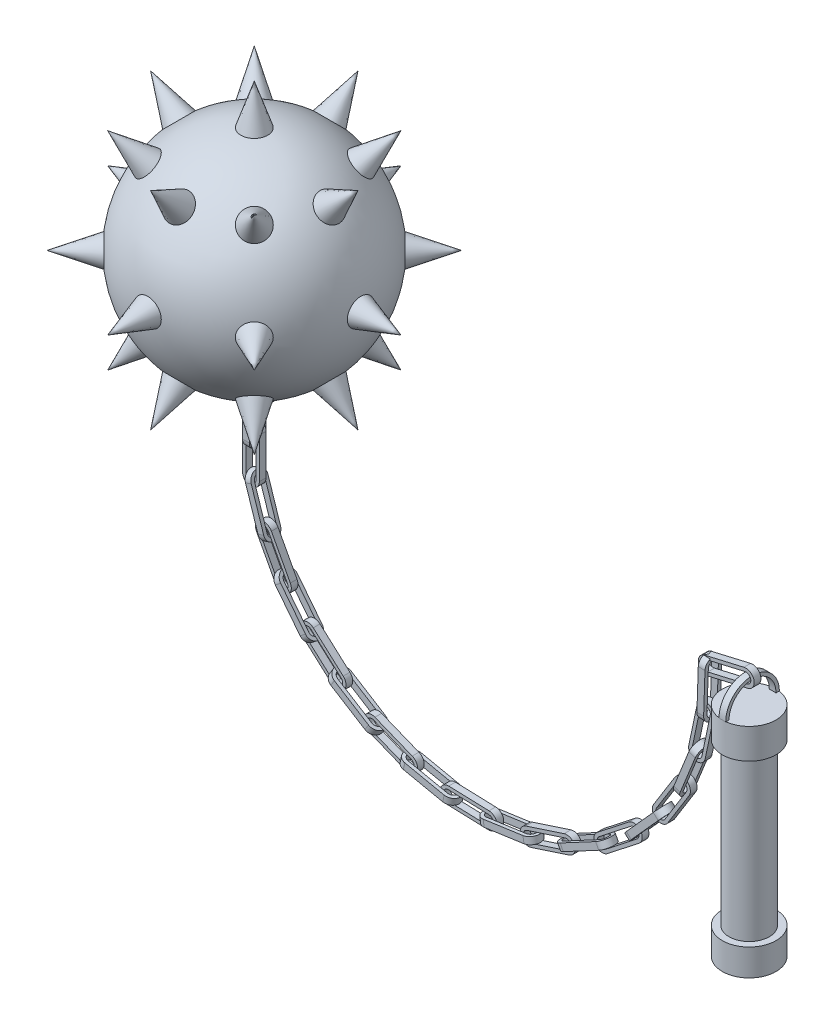
from build123d import *

# Parameters (mm, degrees)
SKETCH16_W                = 25.4
SKETCH16_H                = 3.226223006
BOSS_EXTRUDE1_DEPTH       = 3.175
BOSS_EXTRUDE1_DEPTH_BACK  = 3.175
BOSS_EXTRUDE2_DEPTH       = 3.175
BOSS_EXTRUDE2_DEPTH_BACK  = 3.175
BOSS_EXTRUDE3_DEPTH       = 3.175
BOSS_EXTRUDE3_DEPTH_BACK  = 3.175
BOSS_EXTRUDE4_DEPTH       = 3.175
BOSS_EXTRUDE4_DEPTH_BACK  = 2.54
BOSS_EXTRUDE5_DEPTH       = 3.175
BOSS_EXTRUDE5_DEPTH_BACK  = 3.175
BOSS_EXTRUDE6_DEPTH       = 3.175
BOSS_EXTRUDE6_DEPTH_BACK  = 3.175
BOSS_EXTRUDE7_DEPTH       = 3.175
BOSS_EXTRUDE7_DEPTH_BACK  = 3.175
BOSS_EXTRUDE8_DEPTH       = 3.175
BOSS_EXTRUDE8_DEPTH_BACK  = 3.175
BOSS_EXTRUDE9_DEPTH       = 3.175
BOSS_EXTRUDE9_DEPTH_BACK  = 3.175
BOSS_EXTRUDE10_DEPTH      = 3.175
BOSS_EXTRUDE10_DEPTH_BACK = 3.175
BOSS_EXTRUDE11_DEPTH      = 3.175
BOSS_EXTRUDE11_DEPTH_BACK = 3.175
BOSS_EXTRUDE12_DEPTH      = 3.175
BOSS_EXTRUDE12_DEPTH_BACK = 3.175
BOSS_EXTRUDE13_DEPTH      = 3.175
BOSS_EXTRUDE13_DEPTH_BACK = 3.175
BOSS_EXTRUDE14_DEPTH      = 3.175
BOSS_EXTRUDE14_DEPTH_BACK = 3.175
BOSS_EXTRUDE15_DEPTH      = 3.175
BOSS_EXTRUDE15_DEPTH_BACK = 3.175
BOSS_EXTRUDE16_DEPTH      = 3.175
BOSS_EXTRUDE16_DEPTH_BACK = 3.175
BOSS_EXTRUDE17_DEPTH      = 3.175
BOSS_EXTRUDE17_DEPTH_BACK = 3.175
BOSS_EXTRUDE18_DEPTH      = 3.175
BOSS_EXTRUDE18_DEPTH_BACK = 3.175
BOSS_EXTRUDE19_DEPTH      = 3.175
BOSS_EXTRUDE19_DEPTH_BACK = 3.175
BOSS_EXTRUDE20_DEPTH      = 3.175
BOSS_EXTRUDE20_DEPTH_BACK = 3.175
BOSS_EXTRUDE21_DEPTH      = 3.175
BOSS_EXTRUDE21_DEPTH_BACK = 3.175
SKETCH42_R                = 25.4
BOSS_EXTRUDE22_DEPTH      = 3.175
BOSS_EXTRUDE23_DEPTH      = 3.175
BOSS_EXTRUDE23_DEPTH_BACK = 3.175


with BuildPart() as part:
    # Sketch1 → Revolve1 (revolve)
    with BuildSketch(Plane.XY):
        with BuildLine():
            Line((0, 101.6), (0, -101.6))
            ThreePointArc((0, -101.6), (101.6, 0), (0, 101.6))
        make_face()
    revolve(axis=Axis((0, 101.6, 0), (0, -1, 0)))

    # Sketch6 → Revolve2 (revolve)
    with BuildSketch(Plane.XY, mode=Mode.PRIVATE) as revolve2_sk:
        Polygon((0, 100.803124952), (0, 138.903124952), (12.7, 100.803124952), align=None)
    revolve2 = revolve(revolve2_sk.sketch.rotate(Axis((0, 100.803124952, 0), (0, 1, 0)), 90), axis=Axis((0, 100.803124952, 0), (0, 1, 0)))

    # Mirror1: Revolve2 across plane
    add(revolve2.mirror(Plane(origin=(0, 0, 0), x_dir=(0, 0, 1), z_dir=(0.9238795325112864, -0.3826834323650908, 0))))

    # Mirror2: Revolve2 across plane
    add(revolve2.mirror(Plane(origin=(0, 0, 0), x_dir=(0, 0, 1), z_dir=(-0.3826834323650941, 0.9238795325112851, 0))))

    # Mirror2 copy 1 sketch → Mirror2 copy 1 (revolve)
    with BuildSketch(Plane(origin=(0, 0, 0), x_dir=(0, -1, 0), z_dir=(0, 0, 1))):
        Polygon((0, 100.803124952), (0, 138.903124952), (12.7, 100.803124952), align=None)
    revolve(axis=Axis((100.803124952, 0, 0), (1, 0, 0)))

    # CirPattern2 copy 1 sketch → CirPattern2 copy 1 (revolve)
    with BuildSketch(Plane(origin=(0, 0, 0), x_dir=(-0.49999999999999906, 0.7071067811865491, 0.49999999999999895), z_dir=(0.7071067811865475, 0, 0.7071067811865476))):
        Polygon((0, -100.803124952), (0, -138.903124952), (12.7, -100.803124952), align=None)
    revolve(axis=Axis((50.401562476, 71.278573218, -50.401562476), (-0.5000000000000012, -0.7071067811865459, 0.5000000000000011)))

    # CirPattern2 copy 2 sketch → CirPattern2 copy 2 (revolve)
    with BuildSketch(Plane(origin=(0, 0, 0), x_dir=(0, 0.7071067811865491, 0.7071067811865461), z_dir=(1, 0, 0))):
        Polygon((0, -100.803124952), (0, -138.903124952), (12.7, -100.803124952), align=None)
    revolve(axis=Axis((0, 71.278573218, -71.278573218), (0, -0.7071067811865459, 0.7071067811865491)))

    # CirPattern2 copy 3 sketch → CirPattern2 copy 3 (revolve)
    with BuildSketch(Plane(origin=(0, 0, 0), x_dir=(0.49999999999999895, 0.7071067811865491, 0.49999999999999906), z_dir=(0.7071067811865476, 0, -0.7071067811865475))):
        Polygon((0, -100.803124952), (0, -138.903124952), (12.7, -100.803124952), align=None)
    revolve(axis=Axis((-50.401562476, 71.278573218, -50.401562476), (0.5000000000000011, -0.7071067811865459, 0.5000000000000012)))

    # CirPattern2 copy 4 sketch → CirPattern2 copy 4 (revolve)
    with BuildSketch(Plane(origin=(0, 0, 0), x_dir=(0.7071067811865461, 0.7071067811865491, 0), z_dir=(0, 0, -1))):
        Polygon((0, -100.803124952), (0, -138.903124952), (12.7, -100.803124952), align=None)
    revolve(axis=Axis((-71.278573218, 71.278573218, 0), (0.7071067811865491, -0.7071067811865459, 0)))

    # CirPattern2 copy 5 sketch → CirPattern2 copy 5 (revolve)
    with BuildSketch(Plane(origin=(0, 0, 0), x_dir=(0.4999999999999991, 0.7071067811865491, -0.49999999999999895), z_dir=(-0.7071067811865475, 0, -0.7071067811865477))):
        Polygon((0, -100.803124952), (0, -138.903124952), (12.7, -100.803124952), align=None)
    revolve(axis=Axis((-50.401562476, 71.278573218, 50.401562476), (0.5000000000000012, -0.7071067811865459, -0.5000000000000011)))

    # CirPattern2 copy 6 sketch → CirPattern2 copy 6 (revolve)
    with BuildSketch(Plane(origin=(0, 0, 0), x_dir=(0, 0.7071067811865491, -0.7071067811865461), z_dir=(-1, 0, 0))):
        Polygon((0, -100.803124952), (0, -138.903124952), (12.7, -100.803124952), align=None)
    revolve(axis=Axis((0, 71.278573218, 71.278573218), (0, -0.7071067811865459, -0.7071067811865491)))

    # CirPattern2 copy 7 sketch → CirPattern2 copy 7 (revolve)
    with BuildSketch(Plane(origin=(0, 0, 0), x_dir=(-0.4999999999999989, 0.7071067811865491, -0.4999999999999991), z_dir=(-0.7071067811865477, 0, 0.7071067811865474))):
        Polygon((0, -100.803124952), (0, -138.903124952), (12.7, -100.803124952), align=None)
    revolve(axis=Axis((50.401562476, 71.278573218, 50.401562476), (-0.500000000000001, -0.7071067811865459, -0.5000000000000012)))

    # CirPattern2 copy 8 sketch → CirPattern2 copy 8 (revolve)
    with BuildSketch(Plane(origin=(0, 0, 0), x_dir=(0.7071067811865476, 0, -0.7071067811865475), z_dir=(0.7071067811865475, 0, 0.7071067811865476))):
        Polygon((0, 100.803124952), (0, 138.903124952), (12.7, 100.803124952), align=None)
    revolve(axis=Axis((0, 100.803124952, 0), (0, 1, 0)))

    # CirPattern2 copy 9 sketch → CirPattern2 copy 9 (revolve)
    with BuildSketch(Plane(origin=(0, 0, 0), x_dir=(0, 0, -1), z_dir=(1, 0, 0))):
        Polygon((0, 100.803124952), (0, 138.903124952), (12.7, 100.803124952), align=None)
    revolve(axis=Axis((0, 100.803124952, 0), (0, 1, 0)))

    # CirPattern2 copy 10 sketch → CirPattern2 copy 10 (revolve)
    with BuildSketch(Plane(origin=(0, 0, 0), x_dir=(-0.7071067811865475, 0, -0.7071067811865476), z_dir=(0.7071067811865476, 0, -0.7071067811865475))):
        Polygon((0, 100.803124952), (0, 138.903124952), (12.7, 100.803124952), align=None)
    revolve(axis=Axis((0, 100.803124952, 0), (0, 1, 0)))

    # CirPattern2 copy 11 sketch → CirPattern2 copy 11 (revolve)
    with BuildSketch(Plane(origin=(0, 0, 0), x_dir=(-1, 0, 0), z_dir=(0, 0, -1))):
        Polygon((0, 100.803124952), (0, 138.903124952), (12.7, 100.803124952), align=None)
    revolve(axis=Axis((0, 100.803124952, 0), (0, 1, 0)))

    # CirPattern2 copy 12 sketch → CirPattern2 copy 12 (revolve)
    with BuildSketch(Plane(origin=(0, 0, 0), x_dir=(-0.7071067811865477, 0, 0.7071067811865475), z_dir=(-0.7071067811865475, 0, -0.7071067811865477))):
        Polygon((0, 100.803124952), (0, 138.903124952), (12.7, 100.803124952), align=None)
    revolve(axis=Axis((0, 100.803124952, 0), (0, 1, 0)))

    # CirPattern2 copy 13 sketch → CirPattern2 copy 13 (revolve)
    with BuildSketch(Plane.ZY):
        Polygon((0, 100.803124952), (0, 138.903124952), (12.7, 100.803124952), align=None)
    revolve(axis=Axis((0, 100.803124952, 0), (0, 1, 0)))

    # CirPattern2 copy 14 sketch → CirPattern2 copy 14 (revolve)
    with BuildSketch(Plane(origin=(0, 0, 0), x_dir=(0.7071067811865474, 0, 0.7071067811865477), z_dir=(-0.7071067811865477, 0, 0.7071067811865474))):
        Polygon((0, 100.803124952), (0, 138.903124952), (12.7, 100.803124952), align=None)
    revolve(axis=Axis((0, 100.803124952, 0), (0, 1, 0)))

    # CirPattern2 copy 15 sketch → CirPattern2 copy 15 (revolve)
    with BuildSketch(Plane(origin=(0, 0, 0), x_dir=(0.4999999999999953, 0.7071067811865542, -0.4999999999999952), z_dir=(0.7071067811865475, 0, 0.7071067811865476))):
        Polygon((0, -100.803124952), (0, -138.903124952), (12.7, -100.803124952), align=None)
    revolve(axis=Axis((50.401562476, -71.278573218, -50.401562476), (-0.5000000000000048, 0.7071067811865412, 0.5000000000000047)))

    # CirPattern2 copy 16 sketch → CirPattern2 copy 16 (revolve)
    with BuildSketch(Plane(origin=(0, 0, 0), x_dir=(0, 0.7071067811865542, -0.7071067811865408), z_dir=(1, 0, 0))):
        Polygon((0, -100.803124952), (0, -138.903124952), (12.7, -100.803124952), align=None)
    revolve(axis=Axis((0, -71.278573218, -71.278573218), (0, 0.7071067811865412, 0.7071067811865542)))

    # CirPattern2 copy 17 sketch → CirPattern2 copy 17 (revolve)
    with BuildSketch(Plane(origin=(0, 0, 0), x_dir=(-0.4999999999999952, 0.7071067811865542, -0.4999999999999953), z_dir=(0.7071067811865476, 0, -0.7071067811865475))):
        Polygon((0, -100.803124952), (0, -138.903124952), (12.7, -100.803124952), align=None)
    revolve(axis=Axis((-50.401562476, -71.278573218, -50.401562476), (0.5000000000000047, 0.7071067811865412, 0.5000000000000048)))

    # CirPattern2 copy 18 sketch → CirPattern2 copy 18 (revolve)
    with BuildSketch(Plane(origin=(0, 0, 0), x_dir=(-0.7071067811865408, 0.7071067811865542, 0), z_dir=(0, 0, -1))):
        Polygon((0, -100.803124952), (0, -138.903124952), (12.7, -100.803124952), align=None)
    revolve(axis=Axis((-71.278573218, -71.278573218, 0), (0.7071067811865542, 0.7071067811865412, 0)))

    # CirPattern2 copy 19 sketch → CirPattern2 copy 19 (revolve)
    with BuildSketch(Plane(origin=(0, 0, 0), x_dir=(-0.49999999999999534, 0.7071067811865542, 0.4999999999999952), z_dir=(-0.7071067811865475, 0, -0.7071067811865477))):
        Polygon((0, -100.803124952), (0, -138.903124952), (12.7, -100.803124952), align=None)
    revolve(axis=Axis((-50.401562476, -71.278573218, 50.401562476), (0.5000000000000049, 0.7071067811865412, -0.5000000000000047)))

    # CirPattern2 copy 20 sketch → CirPattern2 copy 20 (revolve)
    with BuildSketch(Plane(origin=(0, 0, 0), x_dir=(0, 0.7071067811865542, 0.7071067811865408), z_dir=(-1, 0, 0))):
        Polygon((0, -100.803124952), (0, -138.903124952), (12.7, -100.803124952), align=None)
    revolve(axis=Axis((0, -71.278573218, 71.278573218), (0, 0.7071067811865412, -0.7071067811865542)))

    # CirPattern2 copy 21 sketch → CirPattern2 copy 21 (revolve)
    with BuildSketch(Plane(origin=(0, 0, 0), x_dir=(0.4999999999999951, 0.7071067811865542, 0.49999999999999534), z_dir=(-0.7071067811865477, 0, 0.7071067811865474))):
        Polygon((0, -100.803124952), (0, -138.903124952), (12.7, -100.803124952), align=None)
    revolve(axis=Axis((50.401562476, -71.278573218, 50.401562476), (-0.5000000000000047, 0.7071067811865412, -0.5000000000000049)))

    # CirPattern2 copy 22 sketch → CirPattern2 copy 22 (revolve)
    with BuildSketch(Plane(origin=(0, 0, 0), x_dir=(0, -1, 0), z_dir=(0.7071067811865475, 0, 0.7071067811865476))):
        Polygon((0, 100.803124952), (0, 138.903124952), (12.7, 100.803124952), align=None)
    revolve(axis=Axis((71.278573218, 0, -71.278573218), (0.7071067811865476, 1.149080830487037e-14, -0.7071067811865475)))

    # CirPattern2 copy 23 sketch → CirPattern2 copy 23 (revolve)
    with BuildSketch(Plane(origin=(0, 0, 0), x_dir=(0, -1, 0), z_dir=(1, 0, 0))):
        Polygon((0, 100.803124952), (0, 138.903124952), (12.7, 100.803124952), align=None)
    revolve(axis=Axis((0, 0, -100.803124952), (0, 0, -1)))

    # CirPattern2 copy 24 sketch → CirPattern2 copy 24 (revolve)
    with BuildSketch(Plane(origin=(0, 0, 0), x_dir=(0, -1, 0), z_dir=(0.7071067811865476, 0, -0.7071067811865475))):
        Polygon((0, 100.803124952), (0, 138.903124952), (12.7, 100.803124952), align=None)
    revolve(axis=Axis((-71.278573218, 0, -71.278573218), (-0.7071067811865475, 1.149080830487037e-14, -0.7071067811865476)))

    # CirPattern2 copy 25 sketch → CirPattern2 copy 25 (revolve)
    with BuildSketch(Plane(origin=(0, 0, 0), x_dir=(0, -1, 0), z_dir=(0, 0, -1))):
        Polygon((0, 100.803124952), (0, 138.903124952), (12.7, 100.803124952), align=None)
    revolve(axis=Axis((-100.803124952, 0, 0), (-1, 0, 0)))

    # CirPattern2 copy 26 sketch → CirPattern2 copy 26 (revolve)
    with BuildSketch(Plane(origin=(0, 0, 0), x_dir=(0, -1, 0), z_dir=(-0.7071067811865475, 0, -0.7071067811865477))):
        Polygon((0, 100.803124952), (0, 138.903124952), (12.7, 100.803124952), align=None)
    revolve(axis=Axis((-71.278573218, 0, 71.278573218), (-0.7071067811865477, 1.149080830487037e-14, 0.7071067811865475)))

    # CirPattern2 copy 27 sketch → CirPattern2 copy 27 (revolve)
    with BuildSketch(Plane(origin=(0, 0, 0), x_dir=(0, -1, 0), z_dir=(-1, 0, 0))):
        Polygon((0, 100.803124952), (0, 138.903124952), (12.7, 100.803124952), align=None)
    revolve(axis=Axis((0, 0, 100.803124952), (0, 0, 1)))

    # CirPattern2 copy 28 sketch → CirPattern2 copy 28 (revolve)
    with BuildSketch(Plane(origin=(0, 0, 0), x_dir=(0, -1, 0), z_dir=(-0.7071067811865477, 0, 0.7071067811865474))):
        Polygon((0, 100.803124952), (0, 138.903124952), (12.7, 100.803124952), align=None)
    revolve(axis=Axis((71.278573218, 0, 71.278573218), (0.7071067811865474, 1.149080830487037e-14, 0.7071067811865477)))

    # CirPattern2 copy 29 sketch → CirPattern2 copy 29 (revolve)
    with BuildSketch(Plane(origin=(0, 0, 0), x_dir=(0.7071067811865476, 0, -0.7071067811865475), z_dir=(0.7071067811865475, 0, 0.7071067811865476))):
        Polygon((0, 100.803124952), (0, 138.903124952), (12.7, 100.803124952), align=None)
    revolve(axis=Axis((0, 100.803124952, 0), (0, 1, 0)))

    # CirPattern2 copy 30 sketch → CirPattern2 copy 30 (revolve)
    with BuildSketch(Plane(origin=(0, 0, 0), x_dir=(0, 0, -1), z_dir=(1, 0, 0))):
        Polygon((0, 100.803124952), (0, 138.903124952), (12.7, 100.803124952), align=None)
    revolve(axis=Axis((0, 100.803124952, 0), (0, 1, 0)))

    # CirPattern2 copy 31 sketch → CirPattern2 copy 31 (revolve)
    with BuildSketch(Plane(origin=(0, 0, 0), x_dir=(-0.7071067811865475, 0, -0.7071067811865476), z_dir=(0.7071067811865476, 0, -0.7071067811865475))):
        Polygon((0, 100.803124952), (0, 138.903124952), (12.7, 100.803124952), align=None)
    revolve(axis=Axis((0, 100.803124952, 0), (0, 1, 0)))

    # CirPattern2 copy 32 sketch → CirPattern2 copy 32 (revolve)
    with BuildSketch(Plane(origin=(0, 0, 0), x_dir=(-1, 0, 0), z_dir=(0, 0, -1))):
        Polygon((0, 100.803124952), (0, 138.903124952), (12.7, 100.803124952), align=None)
    revolve(axis=Axis((0, 100.803124952, 0), (0, 1, 0)))

    # CirPattern2 copy 33 sketch → CirPattern2 copy 33 (revolve)
    with BuildSketch(Plane(origin=(0, 0, 0), x_dir=(-0.7071067811865477, 0, 0.7071067811865475), z_dir=(-0.7071067811865475, 0, -0.7071067811865477))):
        Polygon((0, 100.803124952), (0, 138.903124952), (12.7, 100.803124952), align=None)
    revolve(axis=Axis((0, 100.803124952, 0), (0, 1, 0)))

    # CirPattern2 copy 34 sketch → CirPattern2 copy 34 (revolve)
    with BuildSketch(Plane.ZY):
        Polygon((0, 100.803124952), (0, 138.903124952), (12.7, 100.803124952), align=None)
    revolve(axis=Axis((0, 100.803124952, 0), (0, 1, 0)))

    # CirPattern2 copy 35 sketch → CirPattern2 copy 35 (revolve)
    with BuildSketch(Plane(origin=(0, 0, 0), x_dir=(0.7071067811865474, 0, 0.7071067811865477), z_dir=(-0.7071067811865477, 0, 0.7071067811865474))):
        Polygon((0, 100.803124952), (0, 138.903124952), (12.7, 100.803124952), align=None)
    revolve(axis=Axis((0, 100.803124952, 0), (0, 1, 0)))

    # Sketch16 → Revolve3 (revolve)
    with BuildSketch(Plane.XY):
        with Locations((12.7, -99.986888497)):
            Rectangle(SKETCH16_W, SKETCH16_H)
    revolve(axis=Axis((0, -98.373776994, 0), (0, -1, 0)))

    # Sketch17 → Boss-Extrude1 (add, two sides)
    with BuildSketch(Plane.XY) as boss_extrude1_sk:
        with BuildLine():
            Line((-22.225, -101.6), (-19.05, -101.6))
            ThreePointArc((-19.05, -101.6), (0, -120.65), (19.05, -101.6))
            Line((19.05, -101.6), (22.225, -101.6))
            ThreePointArc((22.225, -101.6), (0, -123.825), (-22.225, -101.6))
        make_face()
    extrude(amount=BOSS_EXTRUDE1_DEPTH)
    extrude(boss_extrude1_sk.sketch, amount=-BOSS_EXTRUDE1_DEPTH_BACK)


with BuildPart() as body_2:
    # Sketch18 → Boss-Extrude2 (new, two sides)
    with BuildSketch(Plane(origin=(0, 0, 0), x_dir=(0, 0, -1), z_dir=(1, 0, 0))) as boss_extrude2_sk:
        with BuildLine():
            Line((7.9375, -114.3), (7.9375, -152.4))
            ThreePointArc((7.9375, -152.4), (0, -160.3375), (-7.9375, -152.4))
            Line((-7.9375, -152.4), (-7.9375, -114.3))
            ThreePointArc((-7.9375, -114.3), (0, -106.3625), (7.9375, -114.3))
        make_face()
        with BuildLine():
            Line((4.7625, -114.3), (4.7625, -152.4))
            ThreePointArc((4.7625, -152.4), (0, -157.1625), (-4.7625, -152.4))
            Line((-4.7625, -152.4), (-4.7625, -114.3))
            ThreePointArc((-4.7625, -114.3), (0, -109.5375), (4.7625, -114.3))
        make_face(mode=Mode.SUBTRACT)
    extrude(amount=BOSS_EXTRUDE2_DEPTH)
    extrude(boss_extrude2_sk.sketch, amount=-BOSS_EXTRUDE2_DEPTH_BACK)


with BuildPart() as body_3:
    # Sketch19 → Boss-Extrude3 (new, two sides)
    with BuildSketch(Plane.XY) as boss_extrude3_sk:
        with BuildLine():
            Line((7.9375, -146.05), (7.9375, -184.15))
            ThreePointArc((7.9375, -184.15), (0, -192.0875), (-7.9375, -184.15))
            Line((-7.9375, -184.15), (-7.9375, -146.05))
            ThreePointArc((-7.9375, -146.05), (0, -138.1125), (7.9375, -146.05))
        make_face()
        with BuildLine():
            Line((4.7625, -146.05), (4.7625, -184.15))
            ThreePointArc((4.7625, -184.15), (0, -188.9125), (-4.7625, -184.15))
            Line((-4.7625, -184.15), (-4.7625, -146.05))
            ThreePointArc((-4.7625, -146.05), (0, -141.2875), (4.7625, -146.05))
        make_face(mode=Mode.SUBTRACT)
    extrude(amount=BOSS_EXTRUDE3_DEPTH)
    extrude(boss_extrude3_sk.sketch, amount=-BOSS_EXTRUDE3_DEPTH_BACK)


with BuildPart() as body_4:
    # Sketch23 → Boss-Extrude4 (new, two sides)
    with BuildSketch(Plane(origin=(-52.514645137, -17.161121629, 0), x_dir=(0, 0, 1), z_dir=(-0.950533423254603, -0.31062229681058945, 0))) as boss_extrude4_sk:
        with BuildLine():
            Line((7.9375, -177.506294373), (7.9375, -215.606294373))
            ThreePointArc((7.9375, -215.606294373), (0, -223.543794373), (-7.9375, -215.606294373))
            Line((-7.9375, -215.606294373), (-7.9375, -177.506294373))
            ThreePointArc((-7.9375, -177.506294373), (0, -169.568794373), (7.9375, -177.506294373))
        make_face()
        with BuildLine():
            Line((4.7625, -177.506294373), (4.7625, -215.606294373))
            ThreePointArc((4.7625, -215.606294373), (0, -220.368794373), (-4.7625, -215.606294373))
            Line((-4.7625, -215.606294373), (-4.7625, -177.506294373))
            ThreePointArc((-4.7625, -177.506294373), (0, -172.743794373), (4.7625, -177.506294373))
        make_face(mode=Mode.SUBTRACT)
    extrude(amount=BOSS_EXTRUDE4_DEPTH)
    extrude(boss_extrude4_sk.sketch, amount=-BOSS_EXTRUDE4_DEPTH_BACK)


with BuildPart() as body_5:
    # Sketch24 → Boss-Extrude5 (new, two sides)
    with BuildSketch(Plane.XY) as boss_extrude5_sk:
        with BuildLine():
            Line((19.347011601, -219.054210709), (37.290650196, -252.664266257))
            ThreePointArc((37.290650196, -252.664266257), (34.026813331, -263.404619204), (23.286460384, -260.140782338))
            Line((23.286460384, -260.140782338), (5.342821789, -226.53072679))
            ThreePointArc((5.342821789, -226.53072679), (8.606658654, -215.790373843), (19.347011601, -219.054210709))
        make_face()
        with BuildLine():
            Line((16.546173638, -220.549513925), (34.489812234, -254.159569473))
            ThreePointArc((34.489812234, -254.159569473), (32.531510114, -260.603781241), (26.087298347, -258.645479122))
            Line((26.087298347, -258.645479122), (8.143659751, -225.035423574))
            ThreePointArc((8.143659751, -225.035423574), (10.101961871, -218.591211806), (16.546173638, -220.549513925))
        make_face(mode=Mode.SUBTRACT)
    extrude(amount=BOSS_EXTRUDE5_DEPTH)
    extrude(boss_extrude5_sk.sketch, amount=-BOSS_EXTRUDE5_DEPTH_BACK)


with BuildPart() as body_6:
    # Sketch25 → Boss-Extrude6 (new, two sides)
    with BuildSketch(Plane(origin=(-104.793813262, -82.159208682, 0), x_dir=(0, 0, 1), z_dir=(-0.7869701611674117, -0.6169910578218603, 0))) as boss_extrude6_sk:
        with BuildLine():
            Line((7.9375, -219.090571228), (7.9375, -257.190571228))
            ThreePointArc((7.9375, -257.190571228), (0, -265.128071228), (-7.9375, -257.190571228))
            Line((-7.9375, -257.190571228), (-7.9375, -219.090571228))
            ThreePointArc((-7.9375, -219.090571228), (0, -211.153071228), (7.9375, -219.090571228))
        make_face()
        with BuildLine():
            Line((4.7625, -219.090571228), (4.7625, -257.190571228))
            ThreePointArc((4.7625, -257.190571228), (0, -261.953071228), (-4.7625, -257.190571228))
            Line((-4.7625, -257.190571228), (-4.7625, -219.090571228))
            ThreePointArc((-4.7625, -219.090571228), (0, -214.328071228), (4.7625, -219.090571228))
        make_face(mode=Mode.SUBTRACT)
    extrude(amount=BOSS_EXTRUDE6_DEPTH)
    extrude(boss_extrude6_sk.sketch, amount=-BOSS_EXTRUDE6_DEPTH_BACK)


with BuildPart() as body_7:
    # Sketch26 → Boss-Extrude7 (new, two sides)
    with BuildSketch(Plane.XY) as boss_extrude7_sk:
        with BuildLine():
            Line((59.032184082, -278.449346859), (87.389004876, -303.895382198))
            ThreePointArc((87.389004876, -303.895382198), (87.995418512, -315.104310559), (76.786490151, -315.710724195))
            Line((76.786490151, -315.710724195), (48.429669357, -290.264688856))
            ThreePointArc((48.429669357, -290.264688856), (47.823255721, -279.055760495), (59.032184082, -278.449346859))
        make_face()
        with BuildLine():
            Line((56.911681137, -280.812415259), (85.268501931, -306.258450597))
            ThreePointArc((85.268501931, -306.258450597), (85.632350113, -312.983807614), (78.906993096, -313.347655796))
            Line((78.906993096, -313.347655796), (50.550172302, -287.901620457))
            ThreePointArc((50.550172302, -287.901620457), (50.186324121, -281.17626344), (56.911681137, -280.812415259))
        make_face(mode=Mode.SUBTRACT)
    extrude(amount=BOSS_EXTRUDE7_DEPTH)
    extrude(boss_extrude7_sk.sketch, amount=-BOSS_EXTRUDE7_DEPTH_BACK)


with BuildPart() as body_8:
    # Sketch27 → Boss-Extrude8 (new, two sides)
    with BuildSketch(Plane(origin=(-116.067521977, -186.446603015, 0), x_dir=(-0.8489415914415972, 0.528486683200824, 0), z_dir=(-0.528486683200824, -0.8489415914415972, 0))) as boss_extrude8_sk:
        with BuildLine():
            Line((-271.514491041, 7.9375), (-233.414491041, 7.9375))
            ThreePointArc((-233.414491041, 7.9375), (-225.476991041, 0), (-233.414491041, -7.9375))
            Line((-233.414491041, -7.9375), (-271.514491041, -7.9375))
            ThreePointArc((-271.514491041, -7.9375), (-279.451991041, 0), (-271.514491041, 7.9375))
        make_face()
        with BuildLine():
            Line((-271.514491041, 4.7625), (-233.414491041, 4.7625))
            ThreePointArc((-233.414491041, 4.7625), (-228.651991041, 0), (-233.414491041, -4.7625))
            Line((-233.414491041, -4.7625), (-271.514491041, -4.7625))
            ThreePointArc((-271.514491041, -4.7625), (-276.276991041, 0), (-271.514491041, 4.7625))
        make_face(mode=Mode.SUBTRACT)
    extrude(amount=BOSS_EXTRUDE8_DEPTH)
    extrude(boss_extrude8_sk.sketch, amount=-BOSS_EXTRUDE8_DEPTH_BACK)


with BuildPart() as body_9:
    # Sketch28 → Boss-Extrude9 (new, two sides)
    with BuildSketch(Plane.XY) as boss_extrude9_sk:
        with BuildLine():
            Line((117.39343209, -322.57386418), (152.743183992, -336.786711904))
            ThreePointArc((152.743183992, -336.786711904), (157.146705696, -347.112253493), (146.821164107, -351.515775197))
            Line((146.821164107, -351.515775197), (111.471412205, -337.302927473))
            ThreePointArc((111.471412205, -337.302927473), (107.067890501, -326.977385884), (117.39343209, -322.57386418))
        make_face()
        with BuildLine():
            Line((116.209028113, -325.519676839), (151.558780015, -339.732524563))
            ThreePointArc((151.558780015, -339.732524563), (154.200893038, -345.927849516), (148.005568084, -348.569962539))
            Line((148.005568084, -348.569962539), (112.655816182, -334.357114814))
            ThreePointArc((112.655816182, -334.357114814), (110.01370316, -328.161789861), (116.209028113, -325.519676839))
        make_face(mode=Mode.SUBTRACT)
    extrude(amount=BOSS_EXTRUDE9_DEPTH)
    extrude(boss_extrude9_sk.sketch, amount=-BOSS_EXTRUDE9_DEPTH_BACK)


with BuildPart() as body_10:
    # Sketch29 → Boss-Extrude10 (new, two sides)
    with BuildSketch(Plane(origin=(-63.086034486, -299.280214714, 0), x_dir=(-0.978497240089968, 0.2062599116074561, 0), z_dir=(-0.20625991160745613, -0.9784972400899681, 0))) as boss_extrude10_sk:
        with BuildLine():
            Line((-255.646048997, 7.9375), (-217.546048997, 7.9375))
            ThreePointArc((-217.546048997, 7.9375), (-209.608548997, 0), (-217.546048997, -7.9375))
            Line((-217.546048997, -7.9375), (-255.646048997, -7.9375))
            ThreePointArc((-255.646048997, -7.9375), (-263.583548997, 0), (-255.646048997, 7.9375))
        make_face()
        with BuildLine():
            Line((-255.646048997, 4.7625), (-217.546048997, 4.7625))
            ThreePointArc((-217.546048997, 4.7625), (-212.783548997, 0), (-217.546048997, -4.7625))
            Line((-217.546048997, -4.7625), (-255.646048997, -4.7625))
            ThreePointArc((-255.646048997, -4.7625), (-260.408548997, 0), (-255.646048997, 4.7625))
        make_face(mode=Mode.SUBTRACT)
    extrude(amount=BOSS_EXTRUDE10_DEPTH)
    extrude(boss_extrude10_sk.sketch, amount=-BOSS_EXTRUDE10_DEPTH_BACK)


with BuildPart() as body_11:
    # Sketch30 → Boss-Extrude11 (new, two sides)
    with BuildSketch(Plane.XY) as boss_extrude11_sk:
        with BuildLine():
            Line((187.326539921, -344.076625094), (225.405521146, -345.342006009))
            ThreePointArc((225.405521146, -345.342006009), (233.075021211, -353.538748121), (224.878279099, -361.208248186))
            Line((224.878279099, -361.208248186), (186.799297874, -359.942867272))
            ThreePointArc((186.799297874, -359.942867272), (179.129797809, -351.746125159), (187.326539921, -344.076625094))
        make_face()
        with BuildLine():
            Line((187.221091512, -347.24987353), (225.300072737, -348.515254444))
            ThreePointArc((225.300072737, -348.515254444), (229.901772776, -353.433299712), (224.983727508, -358.034999751))
            Line((224.983727508, -358.034999751), (186.904746283, -356.769618836))
            ThreePointArc((186.904746283, -356.769618836), (182.303046244, -351.851573569), (187.221091512, -347.24987353))
        make_face(mode=Mode.SUBTRACT)
    extrude(amount=BOSS_EXTRUDE11_DEPTH)
    extrude(boss_extrude11_sk.sketch, amount=-BOSS_EXTRUDE11_DEPTH_BACK)


with BuildPart() as body_12:
    # Sketch31 → Boss-Extrude12 (new, two sides)
    with BuildSketch(Plane(origin=(53.727189599, -377.661093288, 0), x_dir=(-0.9900316805022418, -0.1408448493978644, 0), z_dir=(0.1408448493978644, -0.9900316805022418, 0))) as boss_extrude12_sk:
        with BuildLine():
            Line((-211.240631658, 7.9375), (-173.140631658, 7.9375))
            ThreePointArc((-173.140631658, 7.9375), (-165.203131658, 0), (-173.140631658, -7.9375))
            Line((-173.140631658, -7.9375), (-211.240631658, -7.9375))
            ThreePointArc((-211.240631658, -7.9375), (-219.178131658, 0), (-211.240631658, 7.9375))
        make_face()
        with BuildLine():
            Line((-211.240631658, 4.7625), (-173.140631658, 4.7625))
            ThreePointArc((-173.140631658, 4.7625), (-168.378131658, 0), (-173.140631658, -4.7625))
            Line((-173.140631658, -4.7625), (-211.240631658, -4.7625))
            ThreePointArc((-211.240631658, -4.7625), (-216.003131658, 0), (-211.240631658, 4.7625))
        make_face(mode=Mode.SUBTRACT)
    extrude(amount=BOSS_EXTRUDE12_DEPTH)
    extrude(boss_extrude12_sk.sketch, amount=-BOSS_EXTRUDE12_DEPTH_BACK)


with BuildPart() as body_13:
    # Sketch33 → Boss-Extrude13 (new, two sides)
    with BuildSketch(Plane.XY) as boss_extrude13_sk:
        with BuildLine():
            Line((260.396542669, -340.364079288), (296.611866095, -328.52936978))
            ThreePointArc((296.611866095, -328.52936978), (306.622289623, -333.608664346), (301.542995057, -343.619087874))
            Line((301.542995057, -343.619087874), (265.327671631, -355.453797382))
            ThreePointArc((265.327671631, -355.453797382), (255.317248103, -350.374502816), (260.396542669, -340.364079288))
        make_face()
        with BuildLine():
            Line((261.382768461, -343.382022907), (297.598091887, -331.547313399))
            ThreePointArc((297.598091887, -331.547313399), (303.604346004, -334.594890138), (300.556769264, -340.601144255))
            Line((300.556769264, -340.601144255), (264.341445838, -352.435853764))
            ThreePointArc((264.341445838, -352.435853764), (258.335191721, -349.388277024), (261.382768461, -343.382022907))
        make_face(mode=Mode.SUBTRACT)
    extrude(amount=BOSS_EXTRUDE13_DEPTH)
    extrude(boss_extrude13_sk.sketch, amount=-BOSS_EXTRUDE13_DEPTH_BACK)


with BuildPart() as body_14:
    # Sketch34 → Boss-Extrude14 (new, two sides)
    with BuildSketch(Plane(origin=(205.962414506, -385.786202487, 0), x_dir=(-0.8821536889344881, -0.4709616429172066, 0), z_dir=(0.4709616429172066, -0.8821536889344881, 0))) as boss_extrude14_sk:
        with BuildLine():
            Line((-105.554187709, -7.9375), (-143.654187709, -7.9375))
            ThreePointArc((-143.654187709, -7.9375), (-151.591687709, 0), (-143.654187709, 7.9375))
            Line((-143.654187709, 7.9375), (-105.554187709, 7.9375))
            ThreePointArc((-105.554187709, 7.9375), (-97.616687709, 0), (-105.554187709, -7.9375))
        make_face()
        with BuildLine():
            Line((-105.554187709, -4.7625), (-143.654187709, -4.7625))
            ThreePointArc((-143.654187709, -4.7625), (-148.416687709, 0), (-143.654187709, 4.7625))
            Line((-143.654187709, 4.7625), (-105.554187709, 4.7625))
            ThreePointArc((-105.554187709, 4.7625), (-100.791687709, 0), (-105.554187709, -4.7625))
        make_face(mode=Mode.SUBTRACT)
    extrude(amount=BOSS_EXTRUDE14_DEPTH)
    extrude(boss_extrude14_sk.sketch, amount=-BOSS_EXTRUDE14_DEPTH_BACK)


with BuildPart() as body_15:
    # Sketch35 → Boss-Extrude15 (new, two sides)
    with BuildSketch(Plane.XY) as boss_extrude15_sk:
        with BuildLine():
            Line((327.790119603, -311.884014578), (357.773682743, -288.376655275))
            ThreePointArc((357.773682743, -288.376655275), (368.917624919, -289.725864407), (367.568415786, -300.869806583))
            Line((367.568415786, -300.869806583), (337.584852645, -324.377165886))
            ThreePointArc((337.584852645, -324.377165886), (326.44091047, -323.027956753), (327.790119603, -311.884014578))
        make_face()
        with BuildLine():
            Line((329.749066211, -314.382644839), (359.732629352, -290.875285536))
            ThreePointArc((359.732629352, -290.875285536), (366.418994657, -291.684811016), (365.609469177, -298.371176321))
            Line((365.609469177, -298.371176321), (335.625906037, -321.878535624))
            ThreePointArc((335.625906037, -321.878535624), (328.939540731, -321.069010145), (329.749066211, -314.382644839))
        make_face(mode=Mode.SUBTRACT)
    extrude(amount=BOSS_EXTRUDE15_DEPTH)
    extrude(boss_extrude15_sk.sketch, amount=-BOSS_EXTRUDE15_DEPTH_BACK)


with BuildPart() as body_16:
    # Sketch36 → Boss-Extrude16 (new, two sides)
    with BuildSketch(Plane(origin=(347.350906536, -311.695852896, 0), x_dir=(0, 0, -1), z_dir=(0.7442735116471302, -0.6678749432793906, 0))) as boss_extrude16_sk:
        with BuildLine():
            Line((-7.9375, 22.93863976), (-7.9375, 61.03863976))
            ThreePointArc((-7.9375, 61.03863976), (0, 68.97613976), (7.9375, 61.03863976))
            Line((7.9375, 61.03863976), (7.9375, 22.93863976))
            ThreePointArc((7.9375, 22.93863976), (0, 15.00113976), (-7.9375, 22.93863976))
        make_face()
        with BuildLine():
            Line((-4.7625, 22.93863976), (-4.7625, 61.03863976))
            ThreePointArc((-4.7625, 61.03863976), (0, 65.80113976), (4.7625, 61.03863976))
            Line((4.7625, 61.03863976), (4.7625, 22.93863976))
            ThreePointArc((4.7625, 22.93863976), (0, 18.17613976), (-4.7625, 22.93863976))
        make_face(mode=Mode.SUBTRACT)
    extrude(amount=BOSS_EXTRUDE16_DEPTH)
    extrude(boss_extrude16_sk.sketch, amount=-BOSS_EXTRUDE16_DEPTH_BACK)


with BuildPart() as body_17:
    # Sketch37 → Boss-Extrude17 (new, two sides)
    with BuildSketch(Plane.XY) as boss_extrude17_sk:
        with BuildLine():
            Line((381.378610721, -262.071547087), (401.513953351, -229.726872453))
            ThreePointArc((401.513953351, -229.726872453), (412.447290281, -227.183261619), (414.990901115, -238.116598549))
            Line((414.990901115, -238.116598549), (394.855558485, -270.461273183))
            ThreePointArc((394.855558485, -270.461273183), (383.922221556, -273.004884017), (381.378610721, -262.071547087))
        make_face()
        with BuildLine():
            Line((384.074000274, -263.749492306), (404.209342904, -231.404817672))
            ThreePointArc((404.209342904, -231.404817672), (410.769345062, -229.878651172), (412.295511563, -236.43865333))
            Line((412.295511563, -236.43865333), (392.160168933, -268.783327964))
            ThreePointArc((392.160168933, -268.783327964), (385.600166775, -270.309494464), (384.074000274, -263.749492306))
        make_face(mode=Mode.SUBTRACT)
    extrude(amount=BOSS_EXTRUDE17_DEPTH)
    extrude(boss_extrude17_sk.sketch, amount=-BOSS_EXTRUDE17_DEPTH_BACK)


with BuildPart() as body_18:
    # Sketch38 → Boss-Extrude18 (new, two sides)
    with BuildSketch(Plane(origin=(432.403583671, -173.853731903, 0), x_dir=(0, 0, -1), z_dir=(0.9278150105652632, -0.37304062268039995, 0))) as boss_extrude18_sk:
        with BuildLine():
            Line((-7.9375, -64.741357829), (-7.9375, -26.641357829))
            ThreePointArc((-7.9375, -26.641357829), (0, -18.703857829), (7.9375, -26.641357829))
            Line((7.9375, -26.641357829), (7.9375, -64.741357829))
            ThreePointArc((7.9375, -64.741357829), (0, -72.678857829), (-7.9375, -64.741357829))
        make_face()
        with BuildLine():
            Line((-4.7625, -64.741357829), (-4.7625, -26.641357829))
            ThreePointArc((-4.7625, -26.641357829), (0, -21.878857829), (4.7625, -26.641357829))
            Line((4.7625, -26.641357829), (4.7625, -64.741357829))
            ThreePointArc((4.7625, -64.741357829), (0, -69.503857829), (-4.7625, -64.741357829))
        make_face(mode=Mode.SUBTRACT)
    extrude(amount=BOSS_EXTRUDE18_DEPTH)
    extrude(boss_extrude18_sk.sketch, amount=-BOSS_EXTRUDE18_DEPTH_BACK)


with BuildPart() as body_19:
    # Sketch39 → Boss-Extrude19 (new, two sides)
    with BuildSketch(Plane.XY) as boss_extrude19_sk:
        with BuildLine():
            Line((414.698453114, -196.93479555), (422.556955747, -159.654050703))
            ThreePointArc((422.556955747, -159.654050703), (431.960965638, -153.524416908), (438.090599433, -162.9284268))
            Line((438.090599433, -162.9284268), (430.232096801, -200.209171647))
            ThreePointArc((430.232096801, -200.209171647), (420.828086909, -206.338805442), (414.698453114, -196.93479555))
        make_face()
        with BuildLine():
            Line((417.805181852, -197.58967077), (425.663684484, -160.308925922))
            ThreePointArc((425.663684484, -160.308925922), (431.306090419, -156.631145645), (434.983870696, -162.27355158))
            Line((434.983870696, -162.27355158), (427.125368063, -199.554296428))
            ThreePointArc((427.125368063, -199.554296428), (421.482962128, -203.232076704), (417.805181852, -197.58967077))
        make_face(mode=Mode.SUBTRACT)
    extrude(amount=BOSS_EXTRUDE19_DEPTH)
    extrude(boss_extrude19_sk.sketch, amount=-BOSS_EXTRUDE19_DEPTH_BACK)


with BuildPart() as body_20:
    # Sketch40 → Boss-Extrude20 (new, two sides)
    with BuildSketch(Plane(origin=(435.202976907, -14.461981996, 0), x_dir=(0, 0, -1), z_dir=(0.9994483261180248, -0.0332120974929098, 0))) as boss_extrude20_sk:
        with BuildLine():
            Line((7.9375, -108.810303332), (7.9375, -146.910303332))
            ThreePointArc((7.9375, -146.910303332), (0, -154.847803332), (-7.9375, -146.910303332))
            Line((-7.9375, -146.910303332), (-7.9375, -108.810303332))
            ThreePointArc((-7.9375, -108.810303332), (0, -100.872803332), (7.9375, -108.810303332))
        make_face()
        with BuildLine():
            Line((4.7625, -108.810303332), (4.7625, -146.910303332))
            ThreePointArc((4.7625, -146.910303332), (0, -151.672803332), (-4.7625, -146.910303332))
            Line((-4.7625, -146.910303332), (-4.7625, -108.810303332))
            ThreePointArc((-4.7625, -108.810303332), (0, -104.047803332), (4.7625, -108.810303332))
        make_face(mode=Mode.SUBTRACT)
    extrude(amount=BOSS_EXTRUDE20_DEPTH)
    extrude(boss_extrude20_sk.sketch, amount=-BOSS_EXTRUDE20_DEPTH_BACK)

    # Sketch41 → Boss-Extrude21 (add, two sides)
    with BuildSketch(Plane.XY) as boss_extrude21_sk:
        with BuildLine():
            Line((429.790554035, -115.481220842), (466.899530119, -106.847919388))
            ThreePointArc((466.899530119, -106.847919388), (476.429171272, -112.780351603), (470.496739058, -122.309992756))
            Line((470.496739058, -122.309992756), (433.387762974, -130.94329421))
            ThreePointArc((433.387762974, -130.94329421), (423.85812182, -125.010861996), (429.790554035, -115.481220842))
        make_face()
        with BuildLine():
            Line((430.509995823, -118.573635516), (467.618971907, -109.940334062))
            ThreePointArc((467.618971907, -109.940334062), (473.336756599, -113.499793391), (469.77729727, -119.217578083))
            Line((469.77729727, -119.217578083), (432.668321186, -127.850879537))
            ThreePointArc((432.668321186, -127.850879537), (426.950536494, -124.291420208), (430.509995823, -118.573635516))
        make_face(mode=Mode.SUBTRACT)
    extrude(amount=BOSS_EXTRUDE21_DEPTH)
    extrude(boss_extrude21_sk.sketch, amount=-BOSS_EXTRUDE21_DEPTH_BACK)


with BuildPart() as body_21:
    # Sketch42 → Boss-Extrude22 (new body)
    with BuildSketch(Plane(origin=(0, -138.1125, 0), x_dir=(1, 0, 0), z_dir=(0, 1, 0))):
        with Locations(Location((468.698134588, 0, 0), (0, 0, 270))):
            Circle(SKETCH42_R)
    extrude(amount=-BOSS_EXTRUDE22_DEPTH)

    # Sketch44 → Boss-Extrude23 (add, two sides)
    with BuildSketch(Plane(origin=(468.698134588, 0, 0), x_dir=(0, 0, -1), z_dir=(1, 0, 0))) as boss_extrude23_sk:
        with BuildLine():
            Line((-22.225, -138.1125), (-25.4, -138.1125))
            ThreePointArc((-25.4, -138.1125), (0, -112.7125), (25.4, -138.1125))
            Line((25.4, -138.1125), (22.225, -138.1125))
            ThreePointArc((22.225, -138.1125), (0, -115.8875), (-22.225, -138.1125))
        make_face()
    extrude(amount=BOSS_EXTRUDE23_DEPTH)
    extrude(boss_extrude23_sk.sketch, amount=-BOSS_EXTRUDE23_DEPTH_BACK)

    # Sketch45 → Revolve4 (revolve)
    with BuildSketch(Plane.XY, mode=Mode.PRIVATE) as revolve4_sk:
        Polygon((468.698134588, -141.2875), (468.698134588, -344.4875), (494.098134588, -344.4875), (494.098134588, -319.0875), (487.748134588, -319.0875), (487.748134588, -166.6875), (494.098134588, -166.6875), (494.098134588, -141.2875), align=None)
    revolve(revolve4_sk.sketch.rotate(Axis((468.698134588, -141.2875, 0), (0, -1, 0)), 90), axis=Axis((468.698134588, -141.2875, 0), (0, -1, 0)))


solid = Compound([part.part, body_2.part, body_3.part, body_4.part, body_5.part, body_6.part, body_7.part, body_8.part, body_9.part, body_10.part, body_11.part, body_12.part, body_13.part, body_14.part, body_15.part, body_16.part, body_17.part, body_18.part, body_19.part, body_20.part, body_21.part])
